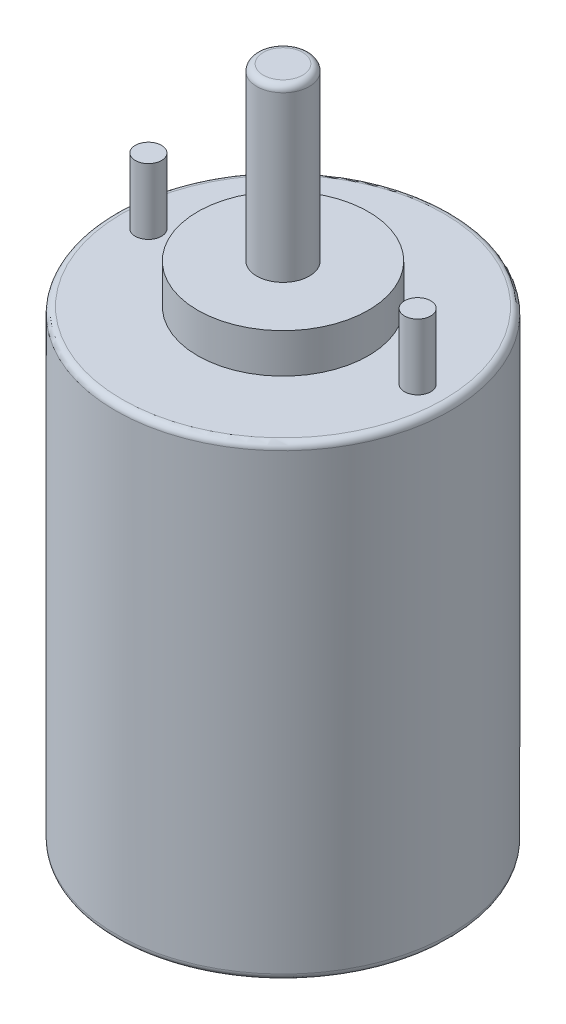
from build123d import *

# Parameters (mm, degrees)
SKETCH2_R            = 25.5
BOSS_EXTRUDE1_DEPTH  = 32.5
SKETCH3_R            = 25.5
BOSS_EXTRUDE2_DEPTH  = 3
FILLET1_R            = 1
SKETCH4_R            = 13
BOSS_EXTRUDE3_DEPTH  = 6
FILLET1_OF_MIRROR1_R = 1
SKETCH5_R            = 4
BOSS_EXTRUDE4_DEPTH  = 26
SKETCH6_R            = 2
BOSS_EXTRUDE5_DEPTH  = 10
FILLET2_R            = 1


with BuildPart() as part:
    # Sketch2 → Boss-Extrude1 (new body, symmetric)
    with BuildSketch(Plane(origin=(0, 0, 0), x_dir=(1, 0, 0), z_dir=(0, 1, 0))):
        Circle(SKETCH2_R)
    extrude(amount=BOSS_EXTRUDE1_DEPTH, both=True)

    # Sketch3 → Boss-Extrude2 (add)
    with BuildSketch(Plane(origin=(0, 32.5, 0), x_dir=(1, 0, 0), z_dir=(0, 1, 0))):
        Circle(SKETCH3_R)
    boss_extrude2 = extrude(amount=BOSS_EXTRUDE2_DEPTH)

    # Fillet1
    fillet1_edges = [part.edges().sort_by_distance(p)[0] for p in [
        (-25.5, 35.5, 0),
    ]]
    fillet(fillet1_edges, radius=FILLET1_R)

    # Sketch4 → Boss-Extrude3 (add)
    with BuildSketch(Plane(origin=(0, 35.5, 0), x_dir=(1, 0, 0), z_dir=(0, 1, 0))):
        Circle(SKETCH4_R)
    boss_extrude3 = extrude(amount=BOSS_EXTRUDE3_DEPTH)

    # Mirror1: Boss-Extrude2, Boss-Extrude3 across plane
    add(boss_extrude2.mirror(Plane.ZX))
    add(boss_extrude3.mirror(Plane.ZX))

    # Fillet1 of Mirror1
    fillet1_of_mirror1_edges = [part.edges().sort_by_distance(p)[0] for p in [
        (-25.5, -35.5, 0),
    ]]
    fillet(fillet1_of_mirror1_edges, radius=FILLET1_OF_MIRROR1_R)

    # Sketch5 → Boss-Extrude4 (add)
    with BuildSketch(Plane(origin=(0, 41.5, 0), x_dir=(1, 0, 0), z_dir=(0, 1, 0))):
        Circle(SKETCH5_R)
    extrude(amount=BOSS_EXTRUDE4_DEPTH)

    # Sketch6 → Boss-Extrude5 (add)
    with BuildSketch(Plane(origin=(0, 35.5, 0), x_dir=(1, 0, 0), z_dir=(0, 1, 0))):
        with Locations((-20.5, 0)):
            Circle(SKETCH6_R)
        with Locations((20.5, 0)):
            Circle(SKETCH6_R)
    extrude(amount=BOSS_EXTRUDE5_DEPTH)

    # Fillet2
    fillet2_edges = [part.edges().sort_by_distance(p)[0] for p in [
        (-4, 67.5, 0),
    ]]
    fillet(fillet2_edges, radius=FILLET2_R)


solid = part.part
